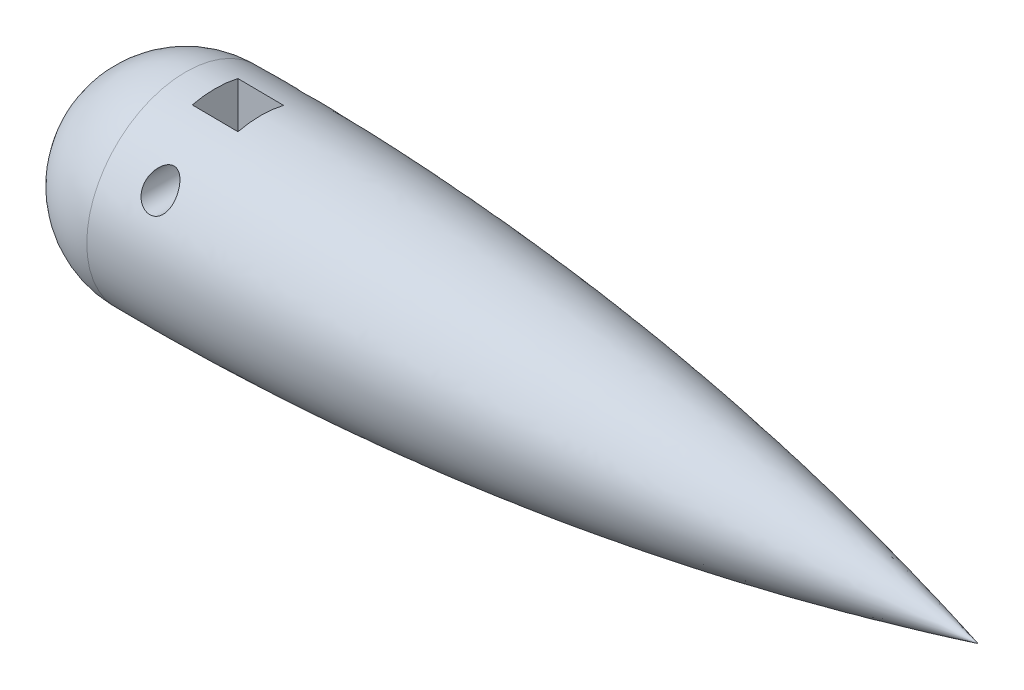
from build123d import *

# Parameters (mm, degrees)
SCALE1_SCALE       = 13.1
SKETCH2_W          = 19.177
SKETCH2_H          = 19.177
CUT_EXTRUDE1_DEPTH = 38.1
SKETCH8_R          = 2.667
CUT_EXTRUDE3_DEPTH = 80.739689811
SKETCH9_R          = 6.35
CUT_EXTRUDE4_DEPTH = 19.05


with BuildPart() as part:
    # Sketch1 → Revolve1 (revolve)
    with BuildSketch(Plane.XY):
        with BuildLine():
            Line((0, 0), (28.575, 0))
            ThreePointArc((28.575, 0), (15.980720366, -2.433262928), (3.175, -3.175))
            ThreePointArc((3.175, -3.175), (0.92993597, -2.24506403), (0, 0))
        make_face()
    revolve(axis=Axis((0, 0, 0), (1, 0, 0)))


with BuildPart() as part_1:
    # Scale1: scaled about (0, 0, 0)
    add(part.part.scale(SCALE1_SCALE))

    # Sketch2 → Cut-Extrude1 (cut)
    with BuildSketch(Plane(origin=(0, 41.91, 0), x_dir=(1, 0, 0), z_dir=(0, 1, 0))):
        with Locations((63.5, 0)):
            Rectangle(SKETCH2_W, SKETCH2_H)
    extrude(amount=-CUT_EXTRUDE1_DEPTH, mode=Mode.SUBTRACT)

    # Sketch8 → Cut-Extrude3 (cut, through all)
    with BuildSketch(Plane(origin=(0, 0, 38.1), x_dir=(-1, 0, 0), z_dir=(0, 0, -1))):
        with Locations((-63.5, 25.4)):
            Circle(SKETCH8_R)
    extrude(amount=CUT_EXTRUDE3_DEPTH, mode=Mode.SUBTRACT)

    # Sketch9 → Cut-Extrude4 (cut)
    with BuildSketch(Plane(origin=(0, 0, 38.1), x_dir=(-1, 0, 0), z_dir=(0, 0, -1))):
        with Locations((-63.5, 25.4)):
            Circle(SKETCH9_R)
    cut_extrude4 = extrude(amount=CUT_EXTRUDE4_DEPTH, mode=Mode.SUBTRACT)

    # Mirror1: Cut-Extrude4 across plane
    add(cut_extrude4.mirror(Plane.XY), mode=Mode.SUBTRACT)


solid = part_1.part
